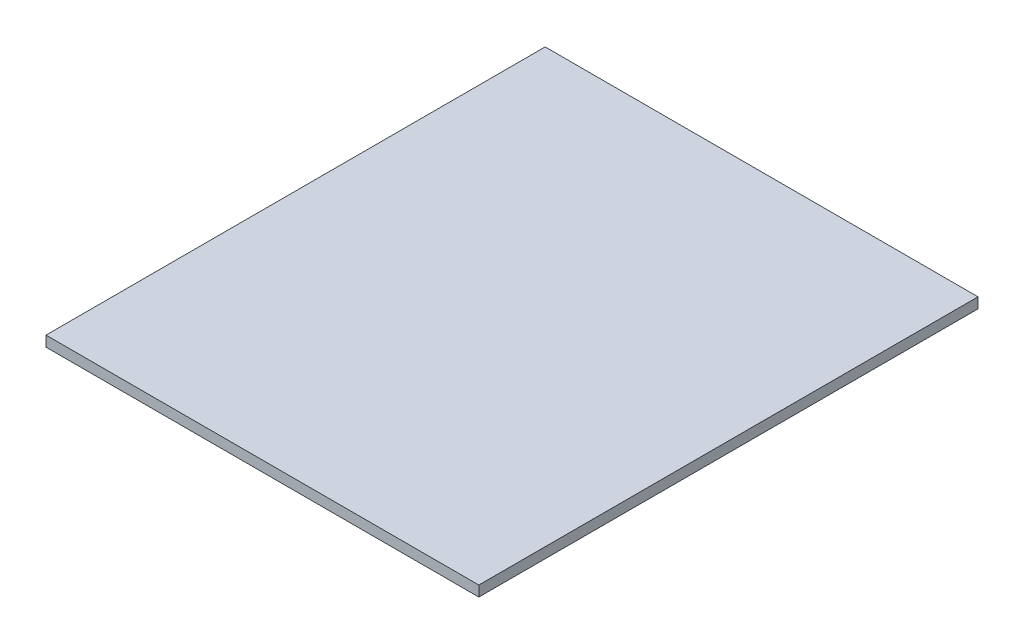
from build123d import *

# Parameters (mm, degrees)
SKETCH1_W           = 248.0112
SKETCH1_H           = 286.0056
BOSS_EXTRUDE1_DEPTH = 5.9944


with BuildPart() as part:
    # Sketch1 → Boss-Extrude1 (new body)
    with BuildSketch(Plane(origin=(0, 0, 0), x_dir=(1, 0, 0), z_dir=(0, 1, 0))):
        with Locations((124.0056, 143.0028)):
            Rectangle(SKETCH1_W, SKETCH1_H)
    extrude(amount=BOSS_EXTRUDE1_DEPTH)


solid = part.part
